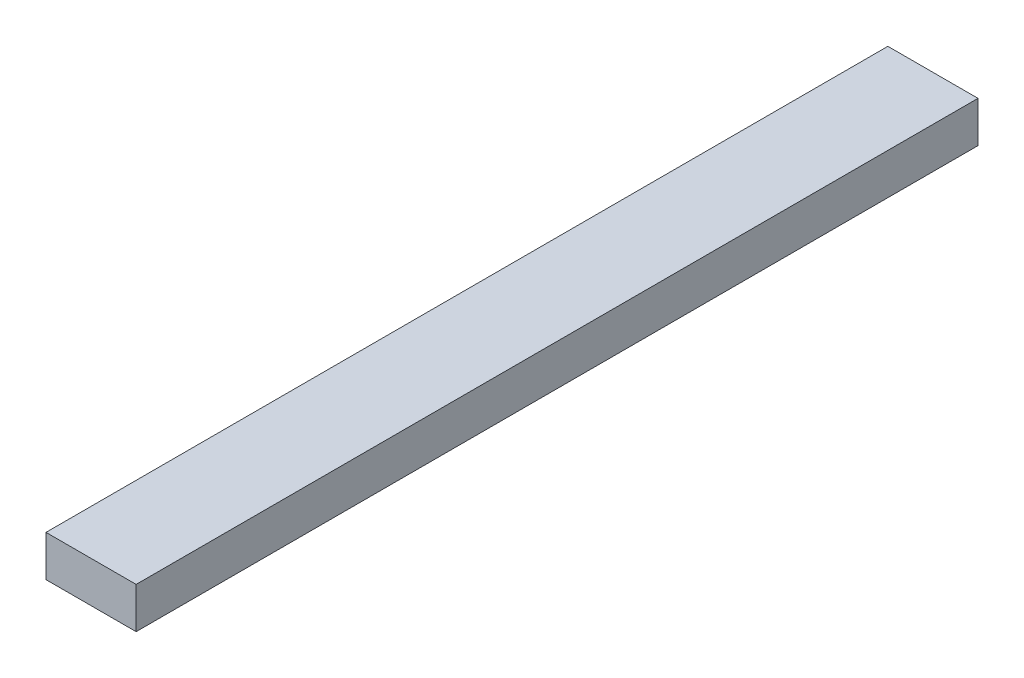
from build123d import *

# Parameters (mm, degrees)
SKETCH1_W           = 44
SKETCH1_H           = 20
BOSS_EXTRUDE1_DEPTH = 411


with BuildPart() as part:
    # Sketch1 → Boss-Extrude1 (new body)
    with BuildSketch(Plane.XY):
        with Locations((22, 10)):
            Rectangle(SKETCH1_W, SKETCH1_H)
    extrude(amount=-BOSS_EXTRUDE1_DEPTH)


solid = part.part
